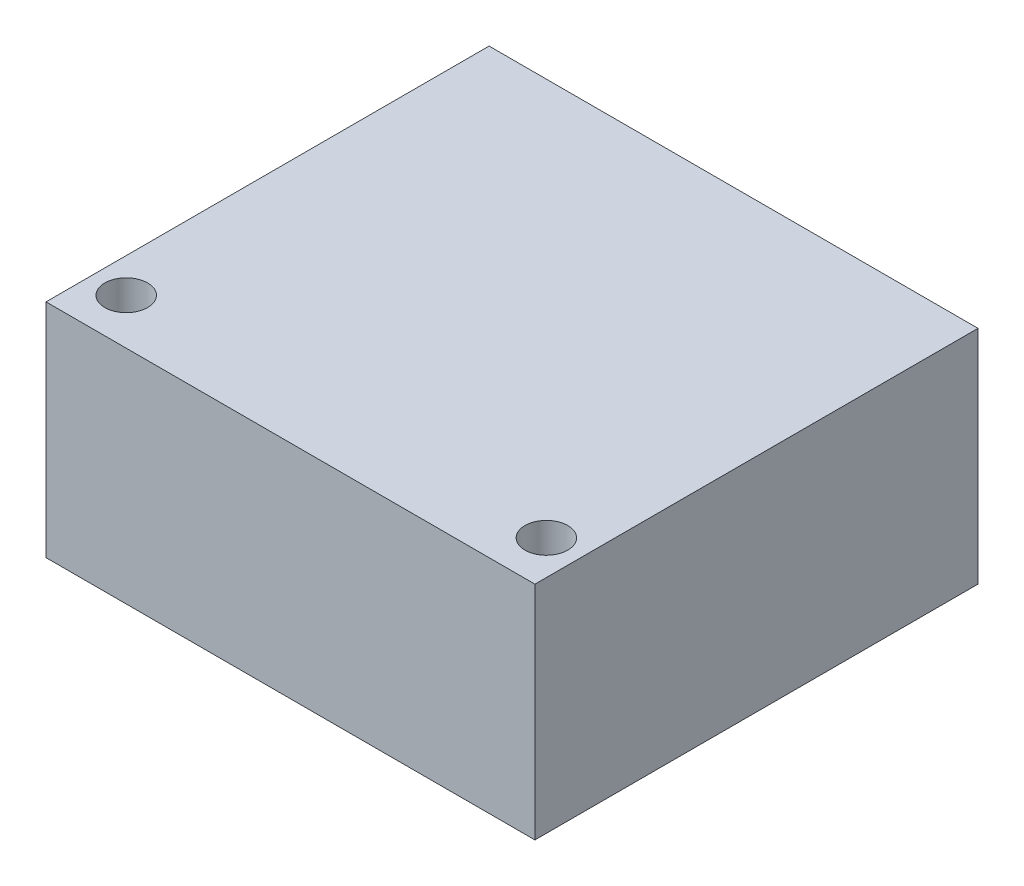
from build123d import *

# Parameters (mm, degrees)
SKETCH_1_W          = 32
SKETCH_1_H          = 29
EXTRUDE_1_DEPTH     = 14.5
SKETCH_2_R          = 1.4
CUT_EXTRUDE_1_DEPTH = 15.5


with BuildPart() as part:
    # 草图1 → 凸台-拉伸1 (new body)
    with BuildSketch(Plane(origin=(0, 0, 0), x_dir=(1, 0, 0), z_dir=(0, 1, 0))):
        Rectangle(SKETCH_1_W, SKETCH_1_H)
    extrude(amount=EXTRUDE_1_DEPTH)

    # 草图2 → 切除-拉伸1 (cut, through all)
    with BuildSketch(Plane(origin=(0, 14.5, 0), x_dir=(1, 0, 0), z_dir=(0, 1, 0))):
        with Locations((-13.75, -11.5)):
            Circle(SKETCH_2_R)
        with Locations((13.75, -11.5)):
            Circle(SKETCH_2_R)
    extrude(amount=-CUT_EXTRUDE_1_DEPTH, mode=Mode.SUBTRACT)


solid = part.part
